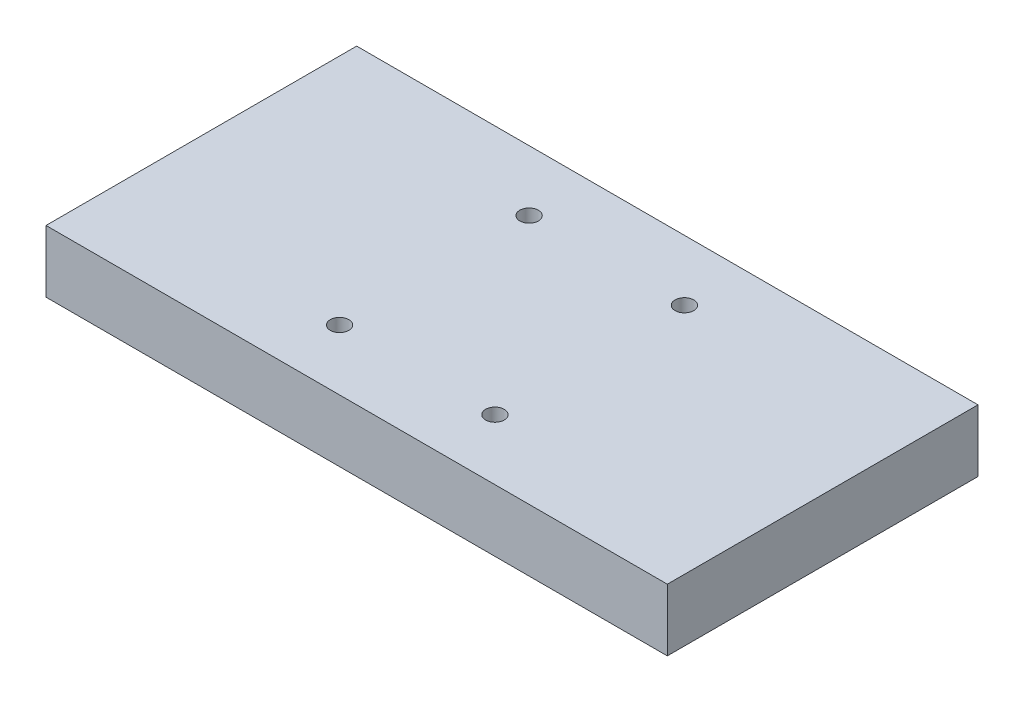
from build123d import *

# Parameters (mm, degrees)
SKETCH1_W           = 200
SKETCH1_H           = 100
BOSS_EXTRUDE1_DEPTH = 20
SKETCH2_R           = 3
CUT_EXTRUDE1_DEPTH  = 20
SKETCH3_R           = 6
CUT_EXTRUDE2_DEPTH  = 10


with BuildPart() as part:
    # Sketch1 → Boss-Extrude1 (new body)
    with BuildSketch(Plane(origin=(0, 0, 0), x_dir=(1, 0, 0), z_dir=(0, 1, 0))):
        Rectangle(SKETCH1_W, SKETCH1_H)
    extrude(amount=BOSS_EXTRUDE1_DEPTH)

    # Sketch2 → Cut-Extrude1 (cut)
    with BuildSketch(Plane(origin=(0, 20, 0), x_dir=(1, 0, 0), z_dir=(0, 1, 0))):
        with Locations((-25, 30.5)):
            Circle(SKETCH2_R)
        with Locations((25, -30.5)):
            Circle(SKETCH2_R)
        with Locations((-25, -30.5)):
            Circle(SKETCH2_R)
        with Locations((25, 30.5)):
            Circle(SKETCH2_R)
    extrude(amount=-CUT_EXTRUDE1_DEPTH, mode=Mode.SUBTRACT)

    # Sketch3 → Cut-Extrude2 (cut)
    with BuildSketch(Plane.XZ):
        with Locations((25, -30.5)):
            Circle(SKETCH3_R)
        with Locations((-25, -30.5)):
            Circle(SKETCH3_R)
        with Locations((25, 30.5)):
            Circle(SKETCH3_R)
        with Locations((-25, 30.5)):
            Circle(SKETCH3_R)
    extrude(amount=-CUT_EXTRUDE2_DEPTH, mode=Mode.SUBTRACT)


solid = part.part
